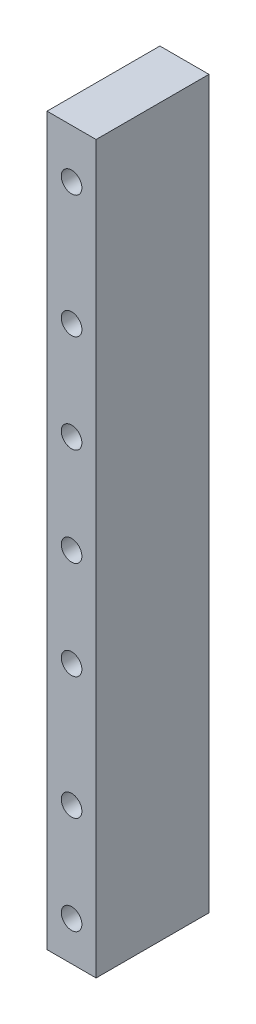
from build123d import *

# Parameters (mm, degrees)
SKETCH1_W           = 10
SKETCH1_H           = 85
BOSS_EXTRUDE2_DEPTH = 5
SKETCH2_W           = 10
SKETCH2_H           = 170
CUT_EXTRUDE1_DEPTH  = 1
SKETCH3_W           = 5
SKETCH3_H           = 8.2
CUT_EXTRUDE2_DEPTH  = 4
BOSS_EXTRUDE3_DEPTH = 9
SKETCH6_W           = 5
SKETCH6_H           = 170
BOSS_EXTRUDE4_DEPTH = 10
SKETCH7_W           = 10
SKETCH7_H           = 170
BOSS_EXTRUDE6_DEPTH = 5
SKETCH9_W           = 10
SKETCH9_H           = 170
BOSS_EXTRUDE7_DEPTH = 5
SKETCH10_R          = 2.1
CUT_EXTRUDE3_DEPTH  = 39
CUT_EXTRUDE6_DEPTH  = 39
SKETCH14_W          = 10
SKETCH14_H          = 2
CUT_EXTRUDE7_DEPTH  = 39


with BuildPart() as part:
    # Sketch1 → Boss-Extrude2 (new body)
    with BuildSketch(Plane.XY):
        with Locations((-75, 0)):
            Rectangle(SKETCH1_W, SKETCH1_H)
        Polygon((-78.6, 10.4), (-75, 8.4), (-71.4, 10.4), (-71.4, 14.6), (-75, 16.6), (-78.6, 14.6), align=None, mode=Mode.SUBTRACT)
        Polygon((-78.6, 34.6), (-78.6, 30.4), (-75, 28.4), (-71.4, 30.4), (-71.4, 34.6), (-75, 36.6), align=None, mode=Mode.SUBTRACT)
        Polygon((-78.6, -10.4), (-78.6, -14.6), (-75, -16.6), (-71.4, -14.6), (-71.4, -10.4), (-75, -8.4), align=None, mode=Mode.SUBTRACT)
        Polygon((-78.6, -34.6), (-75, -36.6), (-71.4, -34.6), (-71.4, -30.4), (-75, -28.4), (-78.6, -30.4), align=None, mode=Mode.SUBTRACT)
        with Locations((-75, 85)):
            Rectangle(SKETCH1_W, SKETCH1_H)
        Polygon((-78.6, 115.4), (-75, 113.4), (-71.4, 115.4), (-71.4, 119.6), (-75, 121.6), (-78.6, 119.6), align=None, mode=Mode.SUBTRACT)
        Polygon((-78.6, 95.4), (-75, 93.4), (-71.4, 95.4), (-71.4, 99.6), (-75, 101.6), (-78.6, 99.6), align=None, mode=Mode.SUBTRACT)
        Polygon((-78.6, 50.4), (-75, 48.4), (-71.4, 50.4), (-71.4, 54.6), (-75, 56.6), (-78.6, 54.6), align=None, mode=Mode.SUBTRACT)
        Polygon((-78.6, 74.6), (-78.6, 70.4), (-75, 68.4), (-71.4, 70.4), (-71.4, 74.6), (-75, 76.6), align=None, mode=Mode.SUBTRACT)
    extrude(amount=BOSS_EXTRUDE2_DEPTH)

    # Sketch2 → Cut-Extrude1 (cut)
    with BuildSketch(Plane(origin=(0, 0, 0), x_dir=(-1, 0, 0), z_dir=(0, 0, -1))):
        with Locations((75, 42.5)):
            Rectangle(SKETCH2_W, SKETCH2_H)
    extrude(amount=-CUT_EXTRUDE1_DEPTH, mode=Mode.SUBTRACT)

    # Sketch3 → Cut-Extrude2 (cut)
    with BuildSketch(Plane(origin=(0, 0, 1), x_dir=(-1, 0, 0), z_dir=(0, 0, -1))):
        with Locations((77.5, 117.5)):
            Rectangle(SKETCH3_W, SKETCH3_H)
        with Locations((77.5, 97.5)):
            Rectangle(SKETCH3_W, SKETCH3_H)
        with Locations((77.5, 72.5)):
            Rectangle(SKETCH3_W, SKETCH3_H)
        with Locations((77.5, 52.5)):
            Rectangle(SKETCH3_W, SKETCH3_H)
        with Locations((77.5, 32.5)):
            Rectangle(SKETCH3_W, SKETCH3_H)
        with Locations((77.5, 12.5)):
            Rectangle(SKETCH3_W, SKETCH3_H)
        with Locations((77.5, -12.5)):
            Rectangle(SKETCH3_W, SKETCH3_H)
        with Locations((77.5, -32.5)):
            Rectangle(SKETCH3_W, SKETCH3_H)
    extrude(amount=-CUT_EXTRUDE2_DEPTH, mode=Mode.SUBTRACT)

    # Sketch5 → Boss-Extrude3 (add)
    with BuildSketch(Plane.XY.offset(5)):
        Polygon((-70, 127.5), (-80, 127.5), (-80, 121.6), (-75, 121.6), (-71.4, 119.6), (-71.4, 115.4), (-75, 113.4), (-80, 113.4), (-80, 101.6), (-75, 101.6), (-71.4, 99.6), (-71.4, 95.4), (-75, 93.4), (-80, 93.4), (-80, 76.6), (-75, 76.6), (-71.4, 74.6), (-71.4, 70.4), (-75, 68.4), (-80, 68.4), (-80, 56.6), (-75, 56.6), (-71.4, 54.6), (-71.4, 50.4), (-75, 48.4), (-80, 48.4), (-80, 36.6), (-75, 36.6), (-71.4, 34.6), (-71.4, 30.4), (-75, 28.4), (-80, 28.4), (-80, 16.6), (-75, 16.6), (-71.4, 14.6), (-71.4, 10.4), (-75, 8.4), (-80, 8.4), (-80, -8.4), (-75, -8.4), (-71.4, -10.4), (-71.4, -14.6), (-75, -16.6), (-80, -16.6), (-80, -28.4), (-75, -28.4), (-71.4, -30.4), (-71.4, -34.6), (-75, -36.6), (-80, -36.6), (-80, -42.5), (-70, -42.5), align=None)
    extrude(amount=BOSS_EXTRUDE3_DEPTH)

    # Sketch6 → Boss-Extrude4 (add)
    with BuildSketch(Plane.ZY.offset(80)):
        with Locations((7.5, 42.5)):
            Rectangle(SKETCH6_W, SKETCH6_H)
    extrude(amount=-BOSS_EXTRUDE4_DEPTH)

    # Sketch7 → Boss-Extrude6 (add)
    with BuildSketch(Plane.XY.offset(14)):
        with Locations((-75, 42.5)):
            Rectangle(SKETCH7_W, SKETCH7_H)
    extrude(amount=BOSS_EXTRUDE6_DEPTH)

    # Sketch9 → Boss-Extrude7 (add)
    with BuildSketch(Plane(origin=(0, 0, 1), x_dir=(-1, 0, 0), z_dir=(0, 0, -1))):
        with Locations((75, 42.5)):
            Rectangle(SKETCH9_W, SKETCH9_H)
    extrude(amount=BOSS_EXTRUDE7_DEPTH)

    # Sketch10 → Cut-Extrude3 (cut)
    with BuildSketch(Plane.XY.offset(19)):
        with Locations((-75, 117.5)):
            Circle(SKETCH10_R)
        with Locations((-75, 97.5)):
            Circle(SKETCH10_R)
        with Locations((-75, 72.5)):
            Circle(SKETCH10_R)
        with Locations((-75, 52.5)):
            Circle(SKETCH10_R)
        with Locations((-75, 32.5)):
            Circle(SKETCH10_R)
        with Locations((-75, 12.5)):
            Circle(SKETCH10_R)
        with Locations((-75, -12.5)):
            Circle(SKETCH10_R)
        with Locations((-75, -32.5)):
            Circle(SKETCH10_R)
    extrude(amount=-CUT_EXTRUDE3_DEPTH, mode=Mode.SUBTRACT)

    # Sketch13 → Cut-Extrude6 (cut)
    with BuildSketch(Plane(origin=(0, 0, -4), x_dir=(-1, 0, 0), z_dir=(0, 0, -1))):
        Polygon((70, 127.5), (75, 127.5), (80, 127.5), (80, 107.5), (75, 107.5), (70, 107.5), align=None)
    extrude(amount=-CUT_EXTRUDE6_DEPTH, mode=Mode.SUBTRACT)

    # Sketch14 → Cut-Extrude7 (cut)
    with BuildSketch(Plane(origin=(0, 0, -4), x_dir=(-1, 0, 0), z_dir=(0, 0, -1))):
        with Locations((75, -41.5)):
            Rectangle(SKETCH14_W, SKETCH14_H)
    extrude(amount=-CUT_EXTRUDE7_DEPTH, mode=Mode.SUBTRACT)


solid = part.part
